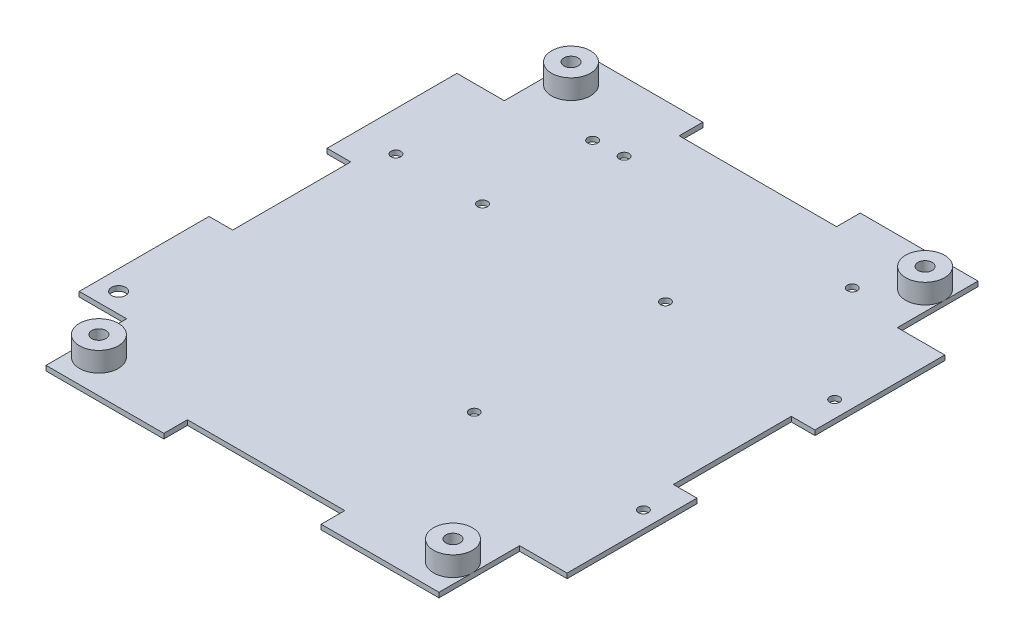
from build123d import *

# Parameters (mm, degrees)
SKETCH1_R            = 2.286
MAIN_BODY_DEPTH      = 1.5875
SKETCH13_R           = 6.28142
SKETCH13_R_2         = 2.286
BOSS_EXTRUDE9_DEPTH  = 6.35
CUT_EXTRUDE3_REACH   = 3.587
SKETCH5_R            = 1.5875
SKETCH5_R_2          = 2.286
SKETCH14_W           = 7.62
SKETCH14_H           = 6.35
BOSS_EXTRUDE10_DEPTH = 1.5875


with BuildPart() as part:
    # Sketch1 → Main Body (new body)
    with BuildSketch(Plane(origin=(0, 0, 0), x_dir=(1, 0, 0), z_dir=(0, 1, 0))):
        Polygon((-25.4, 86.995), (-63.43142, 86.995), (-63.43142, 60.96), (-78.74, 60.96), (-78.74, 25.4), (-71.12, 25.4), (-71.12, -25.4), (-78.74, -25.4), (-78.74, -60.96), (-63.43142, -60.96), (-63.43142, -86.995), (-25.4, -86.995), (-25.4, -79.375), (25.4, -79.375), (25.4, -86.995), (63.43142, -86.995), (63.43142, -60.96), (78.74, -60.96), (78.74, -25.4), (71.12, -25.4), (71.12, 25.4), (78.74, 25.4), (78.74, 60.96), (63.43142, 60.96), (63.43142, 86.995), (25.4, 86.995), (25.4, 79.375), (-25.4, 79.375), align=None)
        with Locations((-57.15, 76.2)):
            Circle(SKETCH1_R, mode=Mode.SUBTRACT)
        with Locations((57.15, 76.2)):
            Circle(SKETCH1_R, mode=Mode.SUBTRACT)
        with Locations((57.15, -76.2)):
            Circle(SKETCH1_R, mode=Mode.SUBTRACT)
        with Locations((-57.15, -76.2)):
            Circle(SKETCH1_R, mode=Mode.SUBTRACT)
    extrude(amount=MAIN_BODY_DEPTH)

    # Sketch13 → Boss-Extrude9 (add)
    with BuildSketch(Plane(origin=(0, 1.5875, 0), x_dir=(1, 0, 0), z_dir=(0, 1, 0))):
        with Locations((-57.15, 76.2)):
            Circle(SKETCH13_R)
        with Locations((-57.15, 76.2)):
            Circle(SKETCH13_R_2, mode=Mode.SUBTRACT)
        with Locations((-57.15, -76.2)):
            Circle(SKETCH13_R)
        with Locations((-57.15, -76.2)):
            Circle(SKETCH13_R_2, mode=Mode.SUBTRACT)
        with Locations((57.15, -76.2)):
            Circle(SKETCH13_R)
        with Locations((57.15, -76.2)):
            Circle(SKETCH13_R_2, mode=Mode.SUBTRACT)
        with Locations((57.15, 76.2)):
            Circle(SKETCH13_R)
        with Locations((57.15, 76.2)):
            Circle(SKETCH13_R_2, mode=Mode.SUBTRACT)
    extrude(amount=BOSS_EXTRUDE9_DEPTH)

    # Sketch5 → Cut-Extrude3 (cut, up to next)
    with BuildSketch(Plane(origin=(0, 1.5875, 0), x_dir=(1, 0, 0), z_dir=(0, 1, 0)), mode=Mode.PRIVATE) as cut_extrude3_sk1:
        with Locations((18.796, 30.734)):
            Circle(SKETCH5_R)
    cut_extrude3_tool1 = extrude(cut_extrude3_sk1.sketch, amount=-CUT_EXTRUDE3_REACH, mode=Mode.PRIVATE) & part.part
    add(cut_extrude3_tool1.solids().sort_by_distance((18.796, 1.5875, -30.734))[0], mode=Mode.SUBTRACT)
    # Sketch5 → Cut-Extrude3 (cut, up to next)
    with BuildSketch(Plane(origin=(0, 1.5875, 0), x_dir=(1, 0, 0), z_dir=(0, 1, 0)), mode=Mode.PRIVATE) as cut_extrude3_sk2:
        with Locations((73.406, 30.734)):
            Circle(SKETCH5_R)
    cut_extrude3_tool2 = extrude(cut_extrude3_sk2.sketch, amount=-CUT_EXTRUDE3_REACH, mode=Mode.PRIVATE) & part.part
    add(cut_extrude3_tool2.solids().sort_by_distance((73.406, 1.5875, -30.734))[0], mode=Mode.SUBTRACT)
    # Sketch5 → Cut-Extrude3 (cut, up to next)
    with BuildSketch(Plane(origin=(0, 1.5875, 0), x_dir=(1, 0, 0), z_dir=(0, 1, 0)), mode=Mode.PRIVATE) as cut_extrude3_sk3:
        with Locations((73.406, -30.988)):
            Circle(SKETCH5_R)
    cut_extrude3_tool3 = extrude(cut_extrude3_sk3.sketch, amount=-CUT_EXTRUDE3_REACH, mode=Mode.PRIVATE) & part.part
    add(cut_extrude3_tool3.solids().sort_by_distance((73.406, 1.5875, 30.988))[0], mode=Mode.SUBTRACT)
    # Sketch5 → Cut-Extrude3 (cut, up to next)
    with BuildSketch(Plane(origin=(0, 1.5875, 0), x_dir=(1, 0, 0), z_dir=(0, 1, 0)), mode=Mode.PRIVATE) as cut_extrude3_sk4:
        with Locations((18.796, -30.988)):
            Circle(SKETCH5_R)
    cut_extrude3_tool4 = extrude(cut_extrude3_sk4.sketch, amount=-CUT_EXTRUDE3_REACH, mode=Mode.PRIVATE) & part.part
    add(cut_extrude3_tool4.solids().sort_by_distance((18.796, 1.5875, 30.988))[0], mode=Mode.SUBTRACT)
    # Sketch5 → Cut-Extrude3 (cut, up to next)
    with BuildSketch(Plane(origin=(0, 1.5875, 0), x_dir=(1, 0, 0), z_dir=(0, 1, 0)), mode=Mode.PRIVATE) as cut_extrude3_sk5:
        with Locations((-28.575, 64.77)):
            Circle(SKETCH5_R)
    cut_extrude3_tool5 = extrude(cut_extrude3_sk5.sketch, amount=-CUT_EXTRUDE3_REACH, mode=Mode.PRIVATE) & part.part
    add(cut_extrude3_tool5.solids().sort_by_distance((-28.575, 1.5875, -64.77))[0], mode=Mode.SUBTRACT)
    # Sketch5 → Cut-Extrude3 (cut, up to next)
    with BuildSketch(Plane(origin=(0, 1.5875, 0), x_dir=(1, 0, 0), z_dir=(0, 1, 0)), mode=Mode.PRIVATE) as cut_extrude3_sk6:
        with Locations((45.085, 64.77)):
            Circle(SKETCH5_R)
    cut_extrude3_tool6 = extrude(cut_extrude3_sk6.sketch, amount=-CUT_EXTRUDE3_REACH, mode=Mode.PRIVATE) & part.part
    add(cut_extrude3_tool6.solids().sort_by_distance((45.085, 1.5875, -64.77))[0], mode=Mode.SUBTRACT)
    # Sketch5 → Cut-Extrude3 (cut, up to next)
    with BuildSketch(Plane(origin=(0, 1.5875, 0), x_dir=(1, 0, 0), z_dir=(0, 1, 0)), mode=Mode.PRIVATE) as cut_extrude3_sk7:
        with Locations((-66.04, 28.575)):
            Circle(SKETCH5_R)
    cut_extrude3_tool7 = extrude(cut_extrude3_sk7.sketch, amount=-CUT_EXTRUDE3_REACH, mode=Mode.PRIVATE) & part.part
    add(cut_extrude3_tool7.solids().sort_by_distance((-66.04, 1.5875, -28.575))[0], mode=Mode.SUBTRACT)
    # Sketch5 → Cut-Extrude3 (cut, up to next)
    with BuildSketch(Plane(origin=(0, 1.5875, 0), x_dir=(1, 0, 0), z_dir=(0, 1, 0)), mode=Mode.PRIVATE) as cut_extrude3_sk8:
        with Locations((-38.1, 64.135)):
            Circle(SKETCH5_R)
    cut_extrude3_tool8 = extrude(cut_extrude3_sk8.sketch, amount=-CUT_EXTRUDE3_REACH, mode=Mode.PRIVATE) & part.part
    add(cut_extrude3_tool8.solids().sort_by_distance((-38.1, 1.5875, -64.135))[0], mode=Mode.SUBTRACT)
    # Sketch5 → Cut-Extrude3 (cut, up to next)
    with BuildSketch(Plane(origin=(0, 1.5875, 0), x_dir=(1, 0, 0), z_dir=(0, 1, 0)), mode=Mode.PRIVATE) as cut_extrude3_sk9:
        with Locations((-38.1, 28.575)):
            Circle(SKETCH5_R)
    cut_extrude3_tool9 = extrude(cut_extrude3_sk9.sketch, amount=-CUT_EXTRUDE3_REACH, mode=Mode.PRIVATE) & part.part
    add(cut_extrude3_tool9.solids().sort_by_distance((-38.1, 1.5875, -28.575))[0], mode=Mode.SUBTRACT)
    # Sketch5 → Cut-Extrude3 (cut, up to next)
    with BuildSketch(Plane(origin=(0, 1.5875, 0), x_dir=(1, 0, 0), z_dir=(0, 1, 0)), mode=Mode.PRIVATE) as cut_extrude3_sk10:
        with Locations((-72.39, -54.61)):
            Circle(SKETCH5_R_2)
    cut_extrude3_tool10 = extrude(cut_extrude3_sk10.sketch, amount=-CUT_EXTRUDE3_REACH, mode=Mode.PRIVATE) & part.part
    add(cut_extrude3_tool10.solids().sort_by_distance((-72.39, 1.5875, 54.61))[0], mode=Mode.SUBTRACT)

    # Sketch14 → Boss-Extrude10 (add)
    with BuildSketch(Plane(origin=(0, 1.5875, 0), x_dir=(1, 0, 0), z_dir=(0, 1, 0))):
        with Locations((-74.93, -22.225)):
            Rectangle(SKETCH14_W, SKETCH14_H)
        with Locations((-74.93, 22.225)):
            Rectangle(SKETCH14_W, SKETCH14_H)
        with Locations((74.93, -22.225)):
            Rectangle(SKETCH14_W, SKETCH14_H)
        with Locations((74.93, 22.225)):
            Rectangle(SKETCH14_W, SKETCH14_H)
    extrude(amount=-BOSS_EXTRUDE10_DEPTH)


solid = part.part
